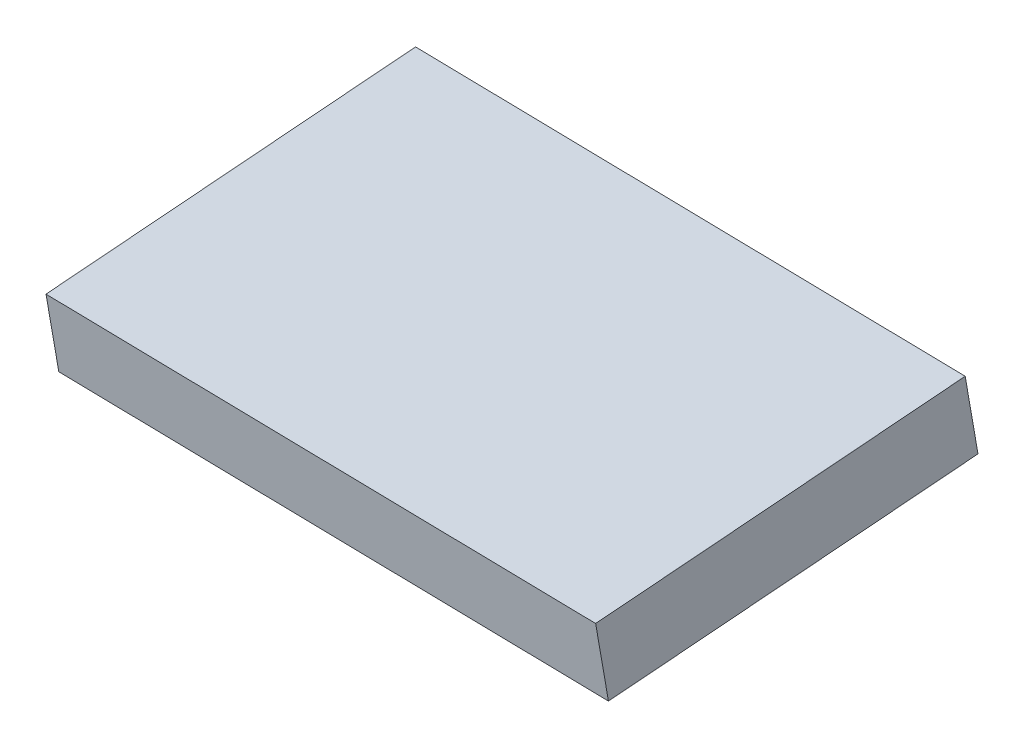
from build123d import *

# Parameters (mm, degrees)
BOSS_EXTRUDE1_DEPTH = 1.524


with BuildPart() as part:
    # Sketch2 → Boss-Extrude1 (new body)
    with BuildSketch(Plane(origin=(-24.580553679, 506.999396267, 67.906919684), x_dir=(-0.998847436, -0.04757309, -0.006371885), z_dir=(0.047997915, -0.990006738, -0.132600371))):
        Polygon((-31.130820698, -50.783202827), (-18.575124968, -50.123783596), (-18.175476949, -57.73329616), (-30.731172679, -58.392715391), align=None)
    extrude(amount=-BOSS_EXTRUDE1_DEPTH)


solid = part.part
